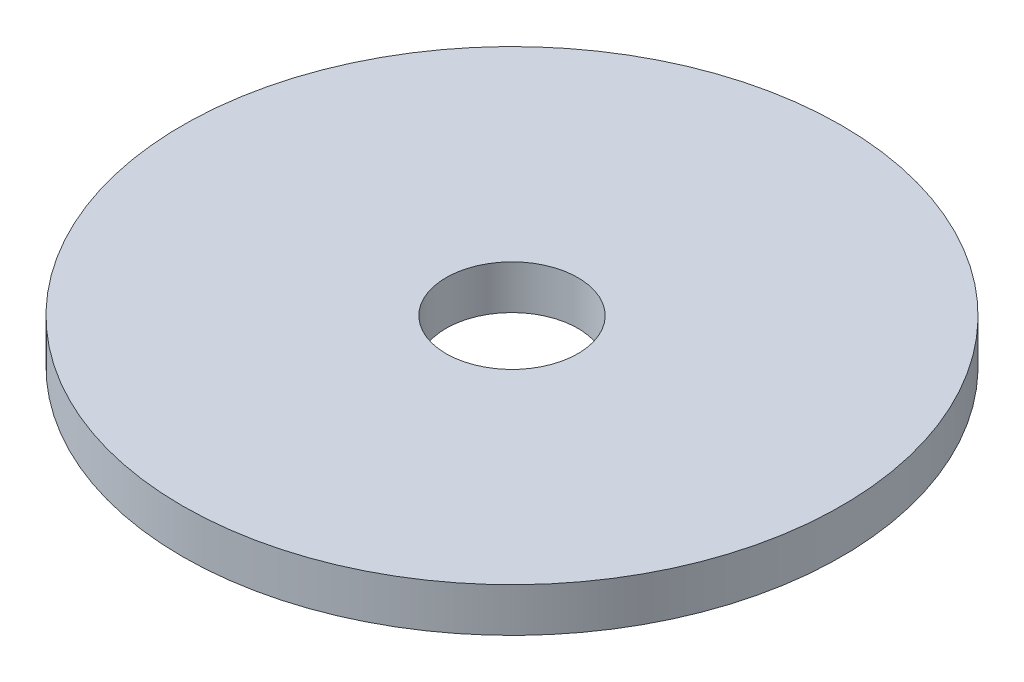
from build123d import *

# Parameters (mm, degrees)
SZKIC2_R                    = 15
DODANIE_WYCI_GNI_CIE1_DEPTH = 2
SZKIC4_R                    = 3
WYTNIJ_WYCI_GNI_CIE1_DEPTH  = 10


with BuildPart() as part:
    # Szkic2 → Dodanie-wyciągnięcie1 (new body)
    with BuildSketch(Plane(origin=(0, 0, 0), x_dir=(1, 0, 0), z_dir=(0, 1, 0))):
        Circle(SZKIC2_R)
    extrude(amount=DODANIE_WYCI_GNI_CIE1_DEPTH)

    # Szkic4 → Wytnij-wyciągnięcie1 (cut)
    with BuildSketch(Plane(origin=(0, 2, 0), x_dir=(1, 0, 0), z_dir=(0, 1, 0))):
        Circle(SZKIC4_R)
    extrude(amount=-WYTNIJ_WYCI_GNI_CIE1_DEPTH, mode=Mode.SUBTRACT)


solid = part.part
